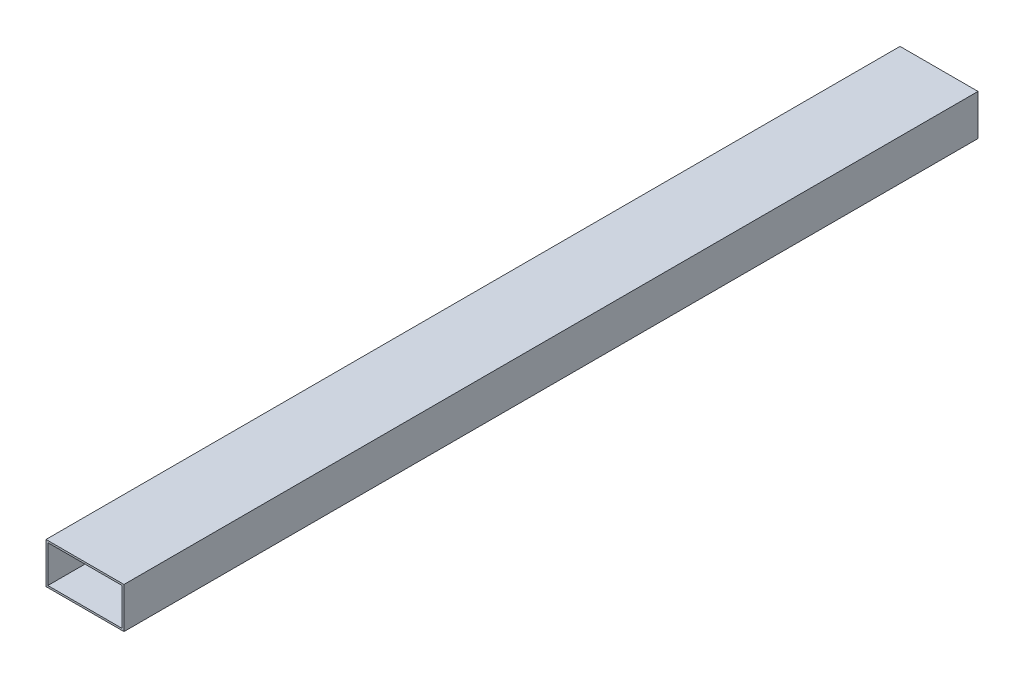
from build123d import *

# Parameters (mm, degrees)
SKETCH1_W           = 42
SKETCH1_H           = 22
SKETCH1_W_2         = 40
SKETCH1_H_2         = 20
BOSS_EXTRUDE1_DEPTH = 460


with BuildPart() as part:
    # Sketch1 → Boss-Extrude1 (new body)
    with BuildSketch(Plane.XY):
        Rectangle(SKETCH1_W, SKETCH1_H)
        Rectangle(SKETCH1_W_2, SKETCH1_H_2, mode=Mode.SUBTRACT)
    extrude(amount=BOSS_EXTRUDE1_DEPTH)


solid = part.part
